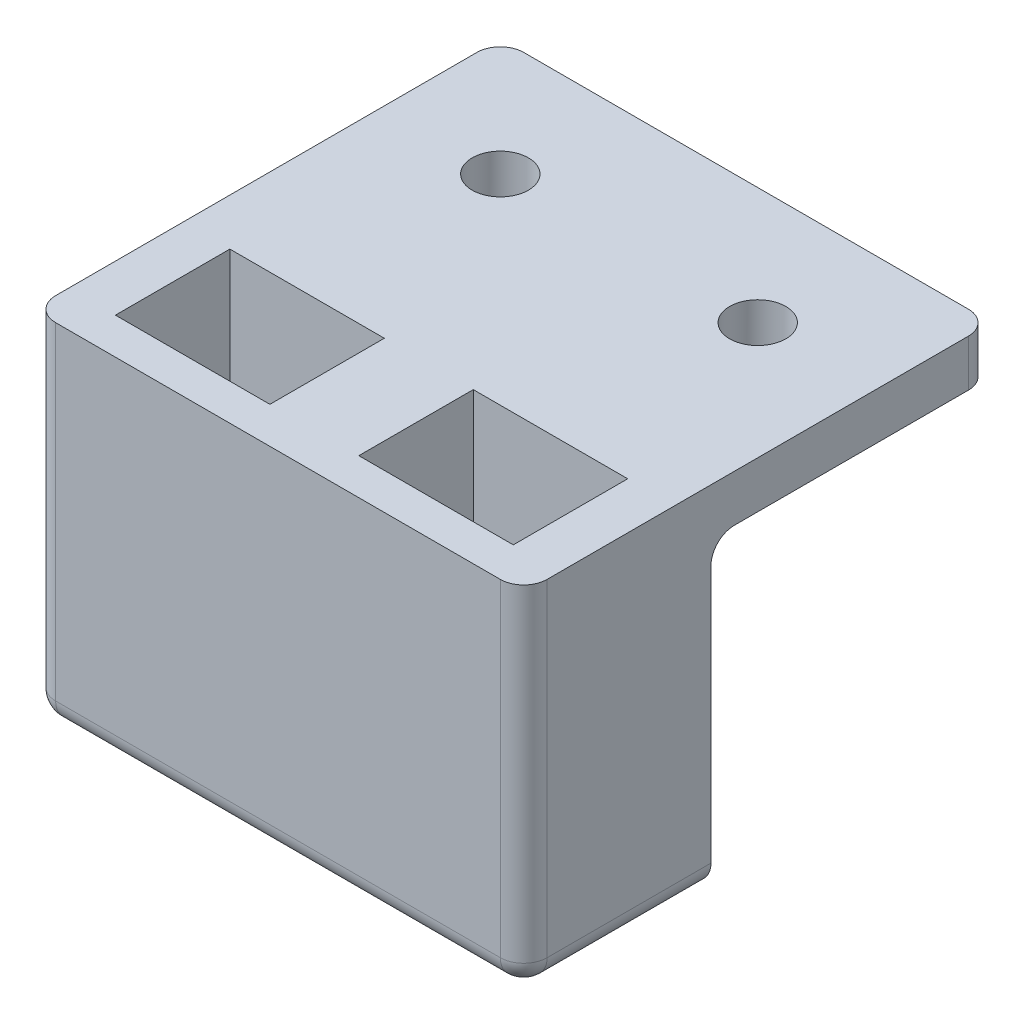
from build123d import *

# Parameters (mm, degrees)
SKETCH1_W              = 21
SKETCH1_H              = 8
MAINBODY_DEPTH         = 15
SKETCH3_W              = 6.6
SKETCH3_H              = 4.89
QRDCLEARANCE_DEPTH     = 12
SKETCH4_W              = 4.6
SKETCH4_H              = 4.89
VISIONTUNNEL_DEPTH     = 3
FILLET1_R              = 1
SKETCH5_W              = 21
SKETCH5_H              = 2
FASTENINGBRACKET_DEPTH = 12
FILLET2_R              = 1
M2_CLEARANCE_HOLE1_D   = 2.4


with BuildPart() as part:
    # Sketch1 → mainBody (new body)
    with BuildSketch(Plane(origin=(0, 0, 0), x_dir=(1, 0, 0), z_dir=(0, 1, 0))):
        with Locations((10.5, 4)):
            Rectangle(SKETCH1_W, SKETCH1_H)
    extrude(amount=MAINBODY_DEPTH)

    # Sketch3 → QRDClearance (cut)
    with BuildSketch(Plane(origin=(0, 15, 0), x_dir=(1, 0, 0), z_dir=(0, 1, 0))):
        with Locations((5.3, 4)):
            Rectangle(SKETCH3_W, SKETCH3_H)
    qrdclearance = extrude(amount=-QRDCLEARANCE_DEPTH, mode=Mode.SUBTRACT)

    # Sketch4 → visionTunnel (cut)
    with BuildSketch(Plane(origin=(0, 3, 0), x_dir=(1, 0, 0), z_dir=(0, 1, 0))):
        with Locations((5.3, 4)):
            Rectangle(SKETCH4_W, SKETCH4_H)
    visiontunnel = extrude(amount=-VISIONTUNNEL_DEPTH, mode=Mode.SUBTRACT)

    # socketMirror: QRDClearance, visionTunnel across plane
    add(qrdclearance.mirror(Plane.ZY.offset(-10.5)), mode=Mode.SUBTRACT)
    add(visiontunnel.mirror(Plane.ZY.offset(-10.5)), mode=Mode.SUBTRACT)

    # Fillet1
    fillet1_edges = [part.edges().sort_by_distance(p)[0] for p in [
        (21, 0, -4),
        (10.5, 0, 0),
        (0, 0, -4),
        (21, 7.5, 0),
        (0, 7.5, 0),
    ]]
    fillet(fillet1_edges, radius=FILLET1_R)

    # Sketch5 → fasteningBracket (add)
    with BuildSketch(Plane(origin=(0, 0, -8), x_dir=(-1, 0, 0), z_dir=(0, 0, -1))):
        with Locations((-10.5, 14)):
            Rectangle(SKETCH5_W, SKETCH5_H)
    extrude(amount=FASTENINGBRACKET_DEPTH)

    # Fillet2
    fillet2_edges = [part.edges().sort_by_distance(p)[0] for p in [
        (0, 14, -20),
        (21, 14, -20),
        (10.5, 13, -8),
    ]]
    fillet(fillet2_edges, radius=FILLET2_R)

    # M2 Clearance Hole1 (through all)
    with Locations(Plane(origin=(5, 15, -15), x_dir=(0, 0, 1), z_dir=(0, 1, 0))):
        with Locations((0, 0), (0, 11)):
            Hole(M2_CLEARANCE_HOLE1_D / 2)


solid = part.part
